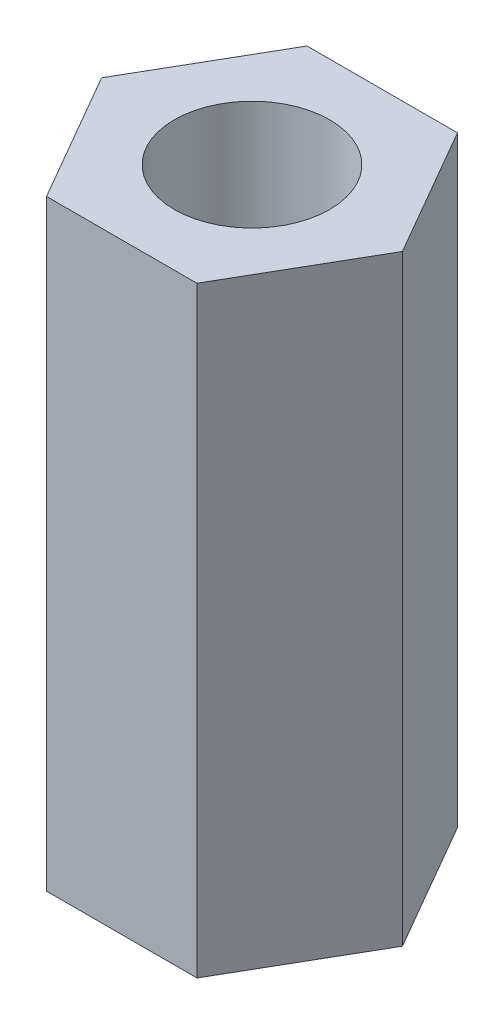
from build123d import *

# Parameters (mm, degrees)
BOSS_EXTRUDE1_DEPTH = 10
SKETCH2_R           = 1.291917854
CUT_EXTRUDE1_DEPTH  = 11


with BuildPart() as part:
    # Sketch1 → Boss-Extrude1 (new body)
    with BuildSketch(Plane(origin=(0, 0, 0), x_dir=(1, 0, 0), z_dir=(0, 1, 0))):
        Polygon((2.5, 0), (1.25, 2.165063509), (-1.25, 2.165063509), (-2.5, 0), (-1.25, -2.165063509), (1.25, -2.165063509), align=None)
    extrude(amount=BOSS_EXTRUDE1_DEPTH)

    # Sketch2 → Cut-Extrude1 (cut, through all)
    with BuildSketch(Plane(origin=(0, 10, 0), x_dir=(1, 0, 0), z_dir=(0, 1, 0))):
        Circle(SKETCH2_R)
    extrude(amount=-CUT_EXTRUDE1_DEPTH, mode=Mode.SUBTRACT)


solid = part.part
